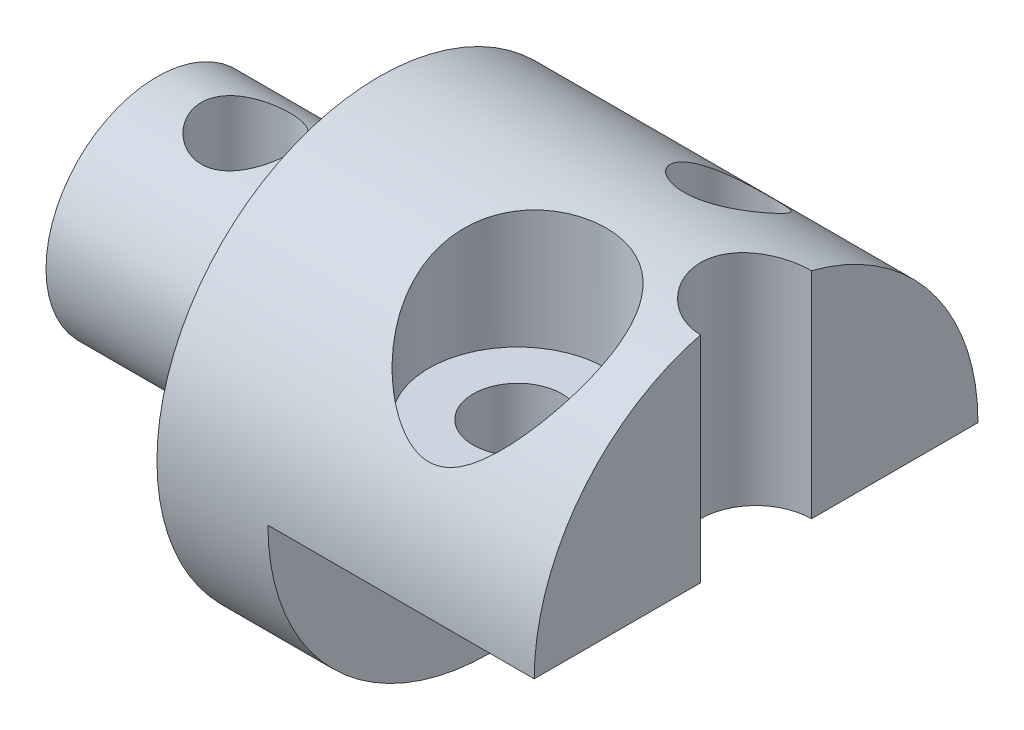
from build123d import *

# Parameters (mm, degrees)
DODANIE_WYCI_GNI_CIE1_DEPTH = 12
SZKIC3_R                    = 2
WYTNIJ_WYCI_GNI_CIE1_DEPTH  = 12
SZKIC5_R                    = 4
WYTNIJ_WYCI_GNI_CIE4_DEPTH  = 10
SZKIC12_R                   = 2.5
WYTNIJ_WYCI_GNI_CIE8_DEPTH  = 11.0000001
SZKIC13_R                   = 2
WYTNIJ_WYCI_GNI_CIE9_DEPTH  = 25.5000001


with BuildPart() as part:
    # Szkic1 → Obrót1 (revolve)
    with BuildSketch(Plane(origin=(0, 0, 0), x_dir=(1, 0, 0), z_dir=(0, 1, 0))):
        Polygon((2.5, -0.875), (2.5, 9.125), (-2.5, 9.125), (-2.5, 4.125), (-12.5, 4.125), (-12.5, -0.875), align=None)
    revolve(axis=Axis((-12.5, 0, 0.875), (1, 0, 0)))

    # Szkic2 → Dodanie-wyciągnięcie1 (add)
    with BuildSketch(Plane(origin=(2.5, 0, 0), x_dir=(0, 0, -1), z_dir=(1, 0, 0))):
        with BuildLine():
            Line((-10.875, 0), (9.125, 0))
            ThreePointArc((9.125, 0), (-0.875, 10), (-10.875, 0))
        make_face()
    extrude(amount=DODANIE_WYCI_GNI_CIE1_DEPTH)

    # Szkic3 → Wytnij-wyciągnięcie1 (cut)
    with BuildSketch(Plane(origin=(0, 0, 0), x_dir=(-1, 0, 0), z_dir=(0, -1, 0))):
        with Locations((-8.5, -5.625)):
            Circle(SZKIC3_R)
        with Locations((-8.5, 3.875)):
            Circle(SZKIC3_R)
    extrude(amount=-WYTNIJ_WYCI_GNI_CIE1_DEPTH, mode=Mode.SUBTRACT)

    # Szkic5 → Wytnij-wyciągnięcie4 (cut)
    with BuildSketch(Plane(origin=(0, 4.5, 0), x_dir=(-1, 0, 0), z_dir=(0, -1, 0))):
        with Locations((-8.5, -5.625)):
            Circle(SZKIC5_R)
    extrude(amount=-WYTNIJ_WYCI_GNI_CIE4_DEPTH, mode=Mode.SUBTRACT)

    # Szkic12 → Wytnij-wyciągnięcie8 (cut, through all)
    with BuildSketch(Plane(origin=(0, 0, 0), x_dir=(1, 0, 0), z_dir=(0, 1, 0))):
        with Locations((14.5, -0.88)):
            Circle(SZKIC12_R)
    extrude(amount=WYTNIJ_WYCI_GNI_CIE8_DEPTH, mode=Mode.SUBTRACT)

    # Szkic13 → Wytnij-wyciągnięcie9 (cut, through all)
    with BuildSketch(Plane(origin=(0, 14.5, 0), x_dir=(1, 0, 0), z_dir=(0, 1, 0))):
        with Locations((-8.5, -0.875)):
            Circle(SZKIC13_R)
    extrude(amount=-WYTNIJ_WYCI_GNI_CIE9_DEPTH, mode=Mode.SUBTRACT)


solid = part.part
